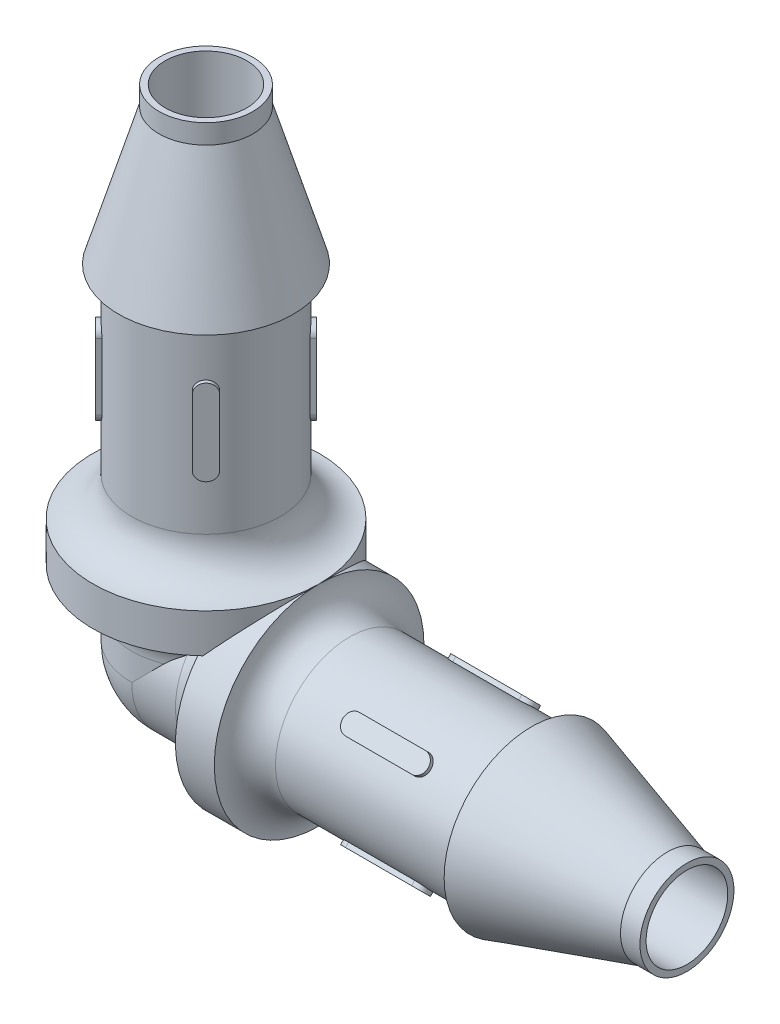
from build123d import *

# Parameters (mm, degrees)
EXTRUDE1_DEPTH     = 2.811018
CIRPATTERN1_COUNT  = 2
CIRPATTERN1_ANGLE  = 90
SKETCH4_R          = 1.4732
CUT_EXTRUDE1_DEPTH = 19.143240542
SKETCH11_R         = 1.4732
CUT_EXTRUDE2_DEPTH = 25.856531955
REVOLVE5_ANGLE     = 90
EXTRUDE2_DEPTH     = 2.811018
CIRPATTERN2_COUNT  = 2
CIRPATTERN2_ANGLE  = 90
SKETCH7_R          = 1.4732
CUT_EXTRUDE4_DEPTH = 25.856531955


with BuildPart() as part:
    # Sketch01 → Revolve1 (revolve)
    with BuildSketch(Plane.XY):
        Polygon((17.33804, 1.4732), (17.33804, 1.69418), (16.637508, 1.69418), (11.733784, 3.1496), (11.733784, 2.67716), (4.078224, 2.67716), (4.078224, 3.77952), (2.67716, 3.77952), (2.67716, 2.67716), (0, 2.67716), (0, 1.4732), align=None)
    revolve(axis=Axis((0, 0, 0), (1, 0, 0)))

    # Sketch2 → Revolve2 (revolve)
    with BuildSketch(Plane.XY):
        with BuildLine():
            Line((5.180584, 2.67716), (4.078224, 2.67716))
            Line((4.078224, 2.67716), (4.078224, 3.77952))
            ThreePointArc((4.078224, 3.77952), (4.401097769, 3.000033769), (5.180584, 2.67716))
        make_face()
        with BuildLine():
            Line((2.67716, 3.77952), (2.67716, 2.67716))
            Line((2.67716, 2.67716), (1.5748, 2.67716))
            ThreePointArc((1.5748, 2.67716), (2.354286231, 3.000033769), (2.67716, 3.77952))
        make_face()
    revolve(axis=Axis((0, 0, 0), (1, 0, 0)))

    # Sketch3 → Extrude1 (add, symmetric)
    with BuildSketch(Plane(origin=(0, 0, 0), x_dir=(-1, 0, 0), z_dir=(0, 0.7071067811865488, 0.7071067811865462))):
        with BuildLine():
            Line((-7.2662796, 0.350266), (-9.6480884, 0.350266))
            ThreePointArc((-9.6480884, 0.350266), (-9.9983544, 0), (-9.6480884, -0.350266))
            Line((-9.6480884, -0.350266), (-7.2662796, -0.350266))
            ThreePointArc((-7.2662796, -0.350266), (-6.9160136, 0), (-7.2662796, 0.350266))
        make_face()
    extrude1 = extrude(amount=EXTRUDE1_DEPTH, both=True)

    # CirPattern1: Extrude1 ×2 about axis
    cirpattern1_axis = Axis((0, 0, 0), (1, 0, 0))
    for i in range(1, CIRPATTERN1_COUNT):
        add(extrude1.rotate(cirpattern1_axis, i * CIRPATTERN1_ANGLE / (CIRPATTERN1_COUNT - 1)))

    # Sketch4 → Cut-Extrude1 (cut, through all)
    with BuildSketch(Plane(origin=(17.33804, 0, 0), x_dir=(0, 0, -1), z_dir=(1, 0, 0))):
        Circle(SKETCH4_R)
    extrude(amount=-CUT_EXTRUDE1_DEPTH, mode=Mode.SUBTRACT)

    # Sketch5 → Revolve3 (revolve)
    with BuildSketch(Plane.XY):
        Polygon((1.4732, 17.33804), (1.69418, 17.33804), (1.69418, 16.637508), (3.1496, 11.733784), (2.67716, 11.733784), (2.67716, 3.77952), (4.078224, 3.77952), (4.078224, 2.378456), (2.67716, 2.378456), (2.67716, 0), (1.4732, 0), align=None)
    revolve(axis=Axis((0, 0, 0), (0, 1, 0)))

    # Sketch10 → Revolve4 (revolve)
    with BuildSketch(Plane.XY):
        with BuildLine():
            Line((4.078224, 3.77952), (2.67716, 3.77952))
            Line((2.67716, 3.77952), (2.67716, 5.180584))
            ThreePointArc((2.67716, 5.180584), (3.087522145, 4.189882145), (4.078224, 3.77952))
        make_face()
        with BuildLine():
            Line((2.67716, 2.378456), (2.67716, 0.977392))
            ThreePointArc((2.67716, 0.977392), (3.087522145, 1.968093855), (4.078224, 2.378456))
            Line((4.078224, 2.378456), (2.67716, 2.378456))
        make_face()
    revolve(axis=Axis((0, 0, 0), (0, 1, 0)))

    # Sketch11 → Cut-Extrude2 (cut, through all)
    with BuildSketch(Plane.ZY):
        Circle(SKETCH11_R)
    extrude(amount=-CUT_EXTRUDE2_DEPTH, mode=Mode.SUBTRACT)

    # Sketch13 → Revolve5 (revolve)
    with BuildSketch(Plane.XZ):
        with BuildLine():
            Line((0, 1.4732), (0, 2.67716))
            ThreePointArc((0, 2.67716), (-2.67716, 0), (0, -2.67716))
            Line((0, -2.67716), (0, -1.4732))
            ThreePointArc((0, -1.4732), (-1.4732, 0), (0, 1.4732))
        make_face()
    revolve(axis=Axis((0, 0, 0), (0, 0, 1)), revolution_arc=REVOLVE5_ANGLE)

    # Sketch9 → Extrude2 (add, symmetric)
    with BuildSketch(Plane(origin=(0, 0, 0), x_dir=(0.7071067811865462, 0, 0.7071067811865488), z_dir=(-0.7071067811865488, 0, 0.7071067811865462))):
        with BuildLine():
            Line((-0.350266, 9.6480884), (-0.350266, 7.2662796))
            ThreePointArc((-0.350266, 7.2662796), (0, 6.9160136), (0.350266, 7.2662796))
            Line((0.350266, 7.2662796), (0.350266, 9.6480884))
            ThreePointArc((0.350266, 9.6480884), (0, 9.9983544), (-0.350266, 9.6480884))
        make_face()
    extrude2 = extrude(amount=EXTRUDE2_DEPTH, both=True)

    # CirPattern2: Extrude2 ×2 about axis
    cirpattern2_axis = Axis((0, 0, 0), (0, 1, 0))
    for i in range(1, CIRPATTERN2_COUNT):
        add(extrude2.rotate(cirpattern2_axis, i * CIRPATTERN2_ANGLE / (CIRPATTERN2_COUNT - 1)))

    # Sketch7 → Cut-Extrude4 (cut, through all)
    with BuildSketch(Plane(origin=(0, 0, 0), x_dir=(1, 0, 0), z_dir=(0, 1, 0))):
        Circle(SKETCH7_R)
    extrude(amount=CUT_EXTRUDE4_DEPTH, mode=Mode.SUBTRACT)


solid = part.part
